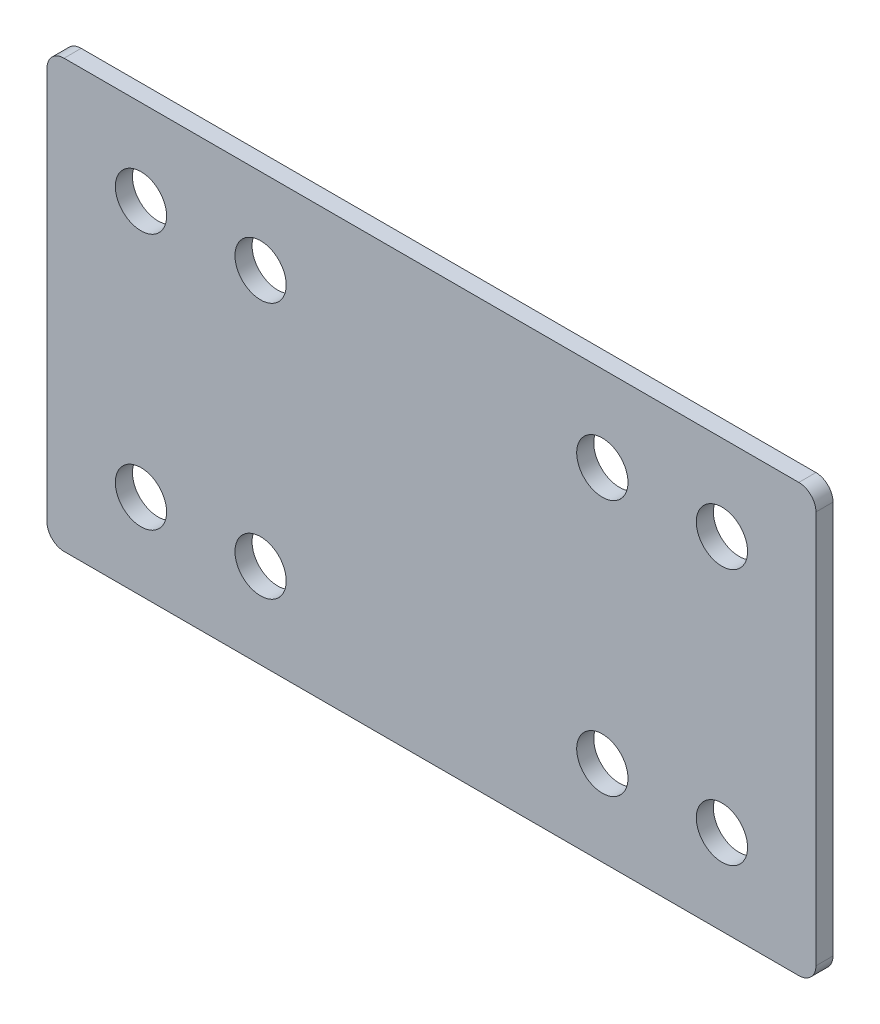
from build123d import *

# Parameters (mm, degrees)
SKETCH1_W           = 45
SKETCH1_H           = 25
BOSS_EXTRUDE1_DEPTH = 1
SKETCH2_R           = 1.5
CUT_EXTRUDE1_DEPTH  = 2
FILLET1_R           = 1


with BuildPart() as part:
    # Sketch1 → Boss-Extrude1 (new body)
    with BuildSketch(Plane.XY):
        Rectangle(SKETCH1_W, SKETCH1_H)
    extrude(amount=BOSS_EXTRUDE1_DEPTH)

    # Sketch2 → Cut-Extrude1 (cut, through all)
    with BuildSketch(Plane.XY.offset(1)):
        with Locations((17, 7.5)):
            Circle(SKETCH2_R)
        with Locations((10, 7.5)):
            Circle(SKETCH2_R)
        with Locations((-17, 7.5)):
            Circle(SKETCH2_R)
        with Locations((-10, 7.5)):
            Circle(SKETCH2_R)
        with Locations((17, -7.5)):
            Circle(SKETCH2_R)
        with Locations((10, -7.5)):
            Circle(SKETCH2_R)
        with Locations((-17, -7.5)):
            Circle(SKETCH2_R)
        with Locations((-10, -7.5)):
            Circle(SKETCH2_R)
    extrude(amount=-CUT_EXTRUDE1_DEPTH, mode=Mode.SUBTRACT)

    # Fillet1
    fillet1_edges = [part.edges().sort_by_distance(p)[0] for p in [
        (22.5, -12.5, 0.5),
        (-22.5, -12.5, 0.5),
        (-22.5, 12.5, 0.5),
        (22.5, 12.5, 0.5),
    ]]
    fillet(fillet1_edges, radius=FILLET1_R)


solid = part.part
